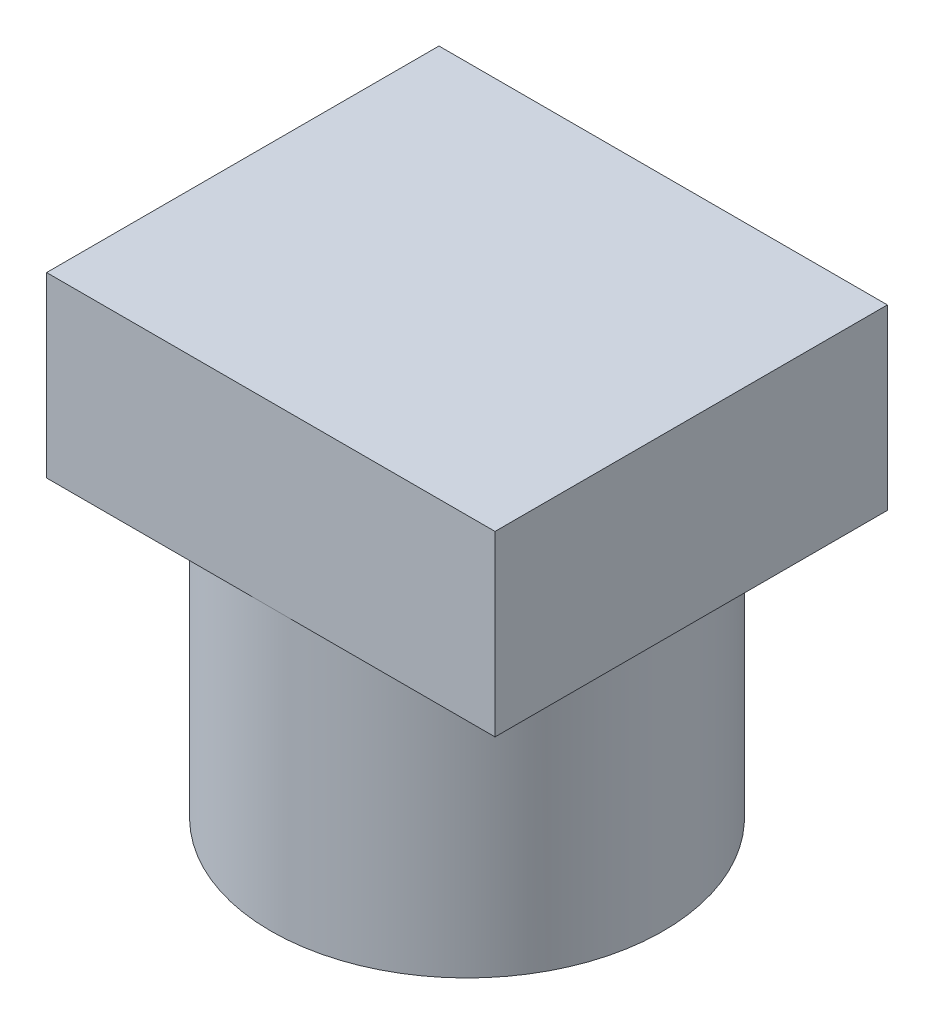
from build123d import *

# Parameters (mm, degrees)
SKETCH1_R           = 3.5
SKETCH1_R_2         = 2
BOSS_EXTRUDE1_DEPTH = 5
SKETCH2_W           = 8
SKETCH2_H           = 7
BOSS_EXTRUDE2_DEPTH = 3.175


with BuildPart() as part:
    # Sketch1 → Boss-Extrude1 (new body)
    with BuildSketch(Plane(origin=(0, 0, 0), x_dir=(1, 0, 0), z_dir=(0, 1, 0))):
        Circle(SKETCH1_R)
        Circle(SKETCH1_R_2, mode=Mode.SUBTRACT)
    extrude(amount=BOSS_EXTRUDE1_DEPTH)

    # Sketch2 → Boss-Extrude2 (add)
    with BuildSketch(Plane(origin=(0, 5, 0), x_dir=(1, 0, 0), z_dir=(0, 1, 0))):
        Rectangle(SKETCH2_W, SKETCH2_H)
    extrude(amount=BOSS_EXTRUDE2_DEPTH)


solid = part.part
